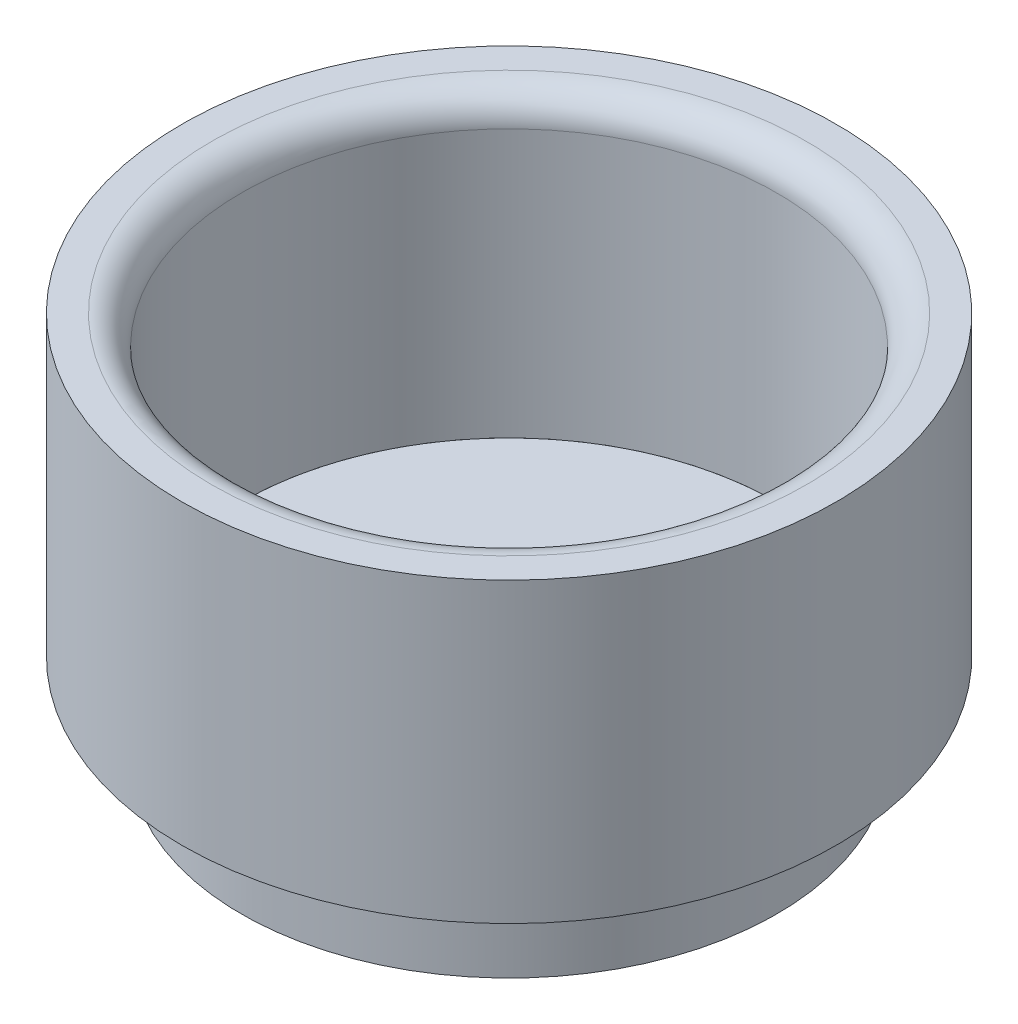
from build123d import *

# Parameters (mm, degrees)
SKETCH1_R           = 11
SKETCH1_R_2         = 9
BOSS_EXTRUDE1_DEPTH = 10
FILLET1_R           = 1
SKETCH2_R           = 9
BOSS_EXTRUDE2_DEPTH = 3


with BuildPart() as part:
    # Sketch1 → Boss-Extrude1 (new body)
    with BuildSketch(Plane(origin=(0, 0, 0), x_dir=(1, 0, 0), z_dir=(0, 1, 0))):
        Circle(SKETCH1_R)
        Circle(SKETCH1_R_2, mode=Mode.SUBTRACT)
    extrude(amount=BOSS_EXTRUDE1_DEPTH)

    # Fillet1
    fillet1_edges = [part.edges().sort_by_distance(p)[0] for p in [
        (-9, 10, 0),
    ]]
    fillet(fillet1_edges, radius=FILLET1_R)


with BuildPart() as body_2:
    # Sketch2 → Boss-Extrude2 (new body)
    with BuildSketch(Plane.XZ):
        Circle(SKETCH2_R)
    extrude(amount=BOSS_EXTRUDE2_DEPTH)


solid = Compound([part.part, body_2.part])
